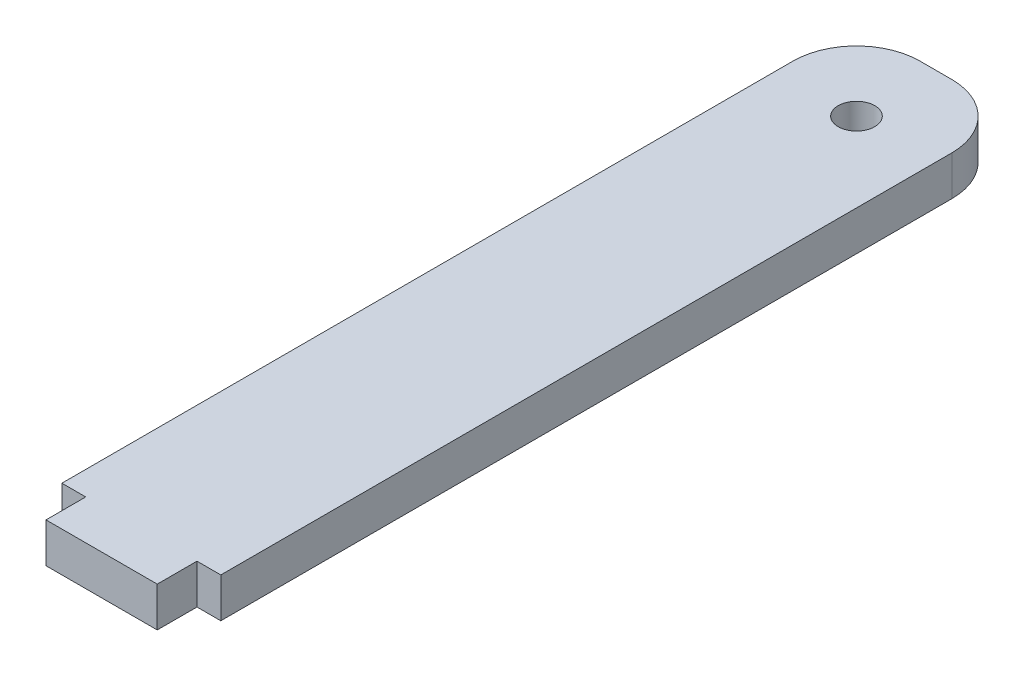
from build123d import *

# Parameters (mm, degrees)
SKETCH2_R           = 1.4605
BOSS_EXTRUDE1_DEPTH = 1.5875
FILLET1_R           = 5.08


with BuildPart() as part:
    # Sketch2 → Boss-Extrude1 (new body, symmetric)
    with BuildSketch(Plane(origin=(0, 0, 0), x_dir=(1, 0, 0), z_dir=(0, 1, 0))):
        Polygon((4.445, -34.925), (4.445, -31.75), (6.35, -31.75), (6.35, 31.75), (-6.35, 31.75), (-6.35, -31.75), (-4.445, -31.75), (-4.445, -34.925), align=None)
        with Locations((0, 25.4)):
            Circle(SKETCH2_R, mode=Mode.SUBTRACT)
    extrude(amount=BOSS_EXTRUDE1_DEPTH, both=True)

    # Fillet1
    fillet1_edges = [part.edges().sort_by_distance(p)[0] for p in [
        (6.35, 0, -31.75),
        (-6.35, 0, -31.75),
    ]]
    fillet(fillet1_edges, radius=FILLET1_R)


solid = part.part
